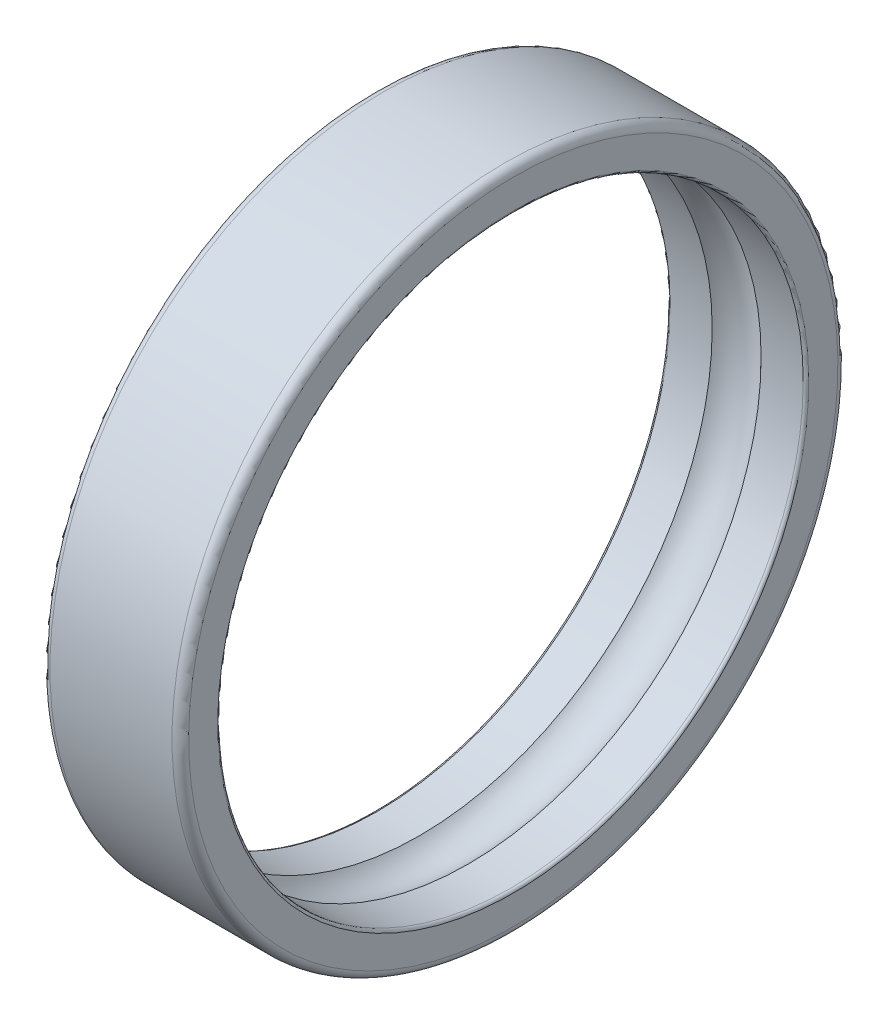
from build123d import *


with BuildPart() as part:
    # Sketch1 → Revolve1 (revolve)
    with BuildSketch(Plane.XY):
        with BuildLine():
            Line((0, 11.7), (0, 10.65))
            ThreePointArc((0, 10.65), (0.029289322, 10.579289322), (0.1, 10.55))
            Line((0.1, 10.55), (1.618359342, 10.55))
            ThreePointArc((1.618359342, 10.55), (2.5, 10.9405), (3.381640658, 10.55))
            Line((3.381640658, 10.55), (4.9, 10.55))
            ThreePointArc((4.9, 10.55), (4.970710678, 10.579289322), (5, 10.65))
            Line((5, 10.65), (5, 11.7))
            ThreePointArc((5, 11.7), (4.912132034, 11.912132034), (4.7, 12))
            Line((4.7, 12), (0.3, 12))
            ThreePointArc((0.3, 12), (0.087867966, 11.912132034), (0, 11.7))
        make_face()
    revolve(axis=Axis((5, 0, 0), (-1, 0, 0)))


solid = part.part
